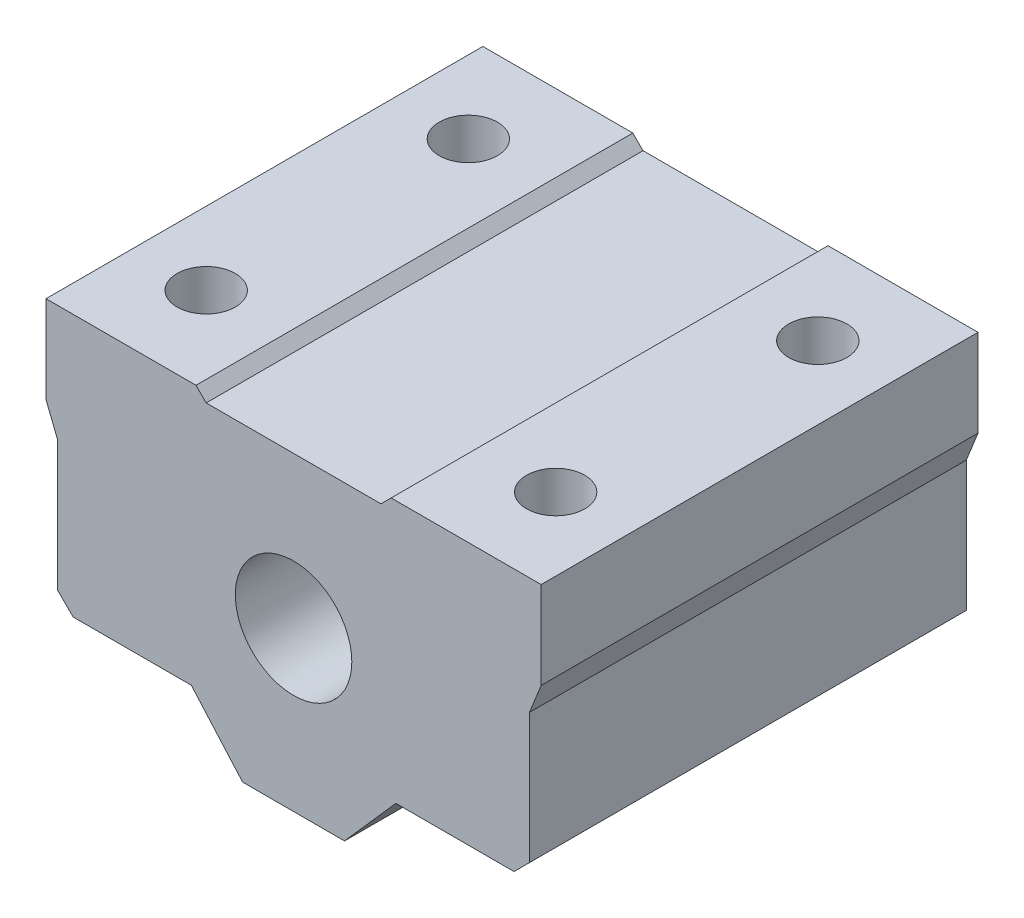
from build123d import *

# Parameters (mm, degrees)
SKETCH1_R           = 7.5
SKETCH1_R_2         = 4
BOSS_EXTRUDE1_DEPTH = 30
SKETCH4_R           = 2
CUT_EXTRUDE1_DEPTH  = 19


with BuildPart() as part:
    # Sketch1 → Boss-Extrude1 (new body)
    with BuildSketch(Plane.XY):
        Polygon((6.7, 11.09607963), (17, 11.09607963), (17, 5.09607963), (16.2, 3.09607963), (16.2, -5.843260198), (15.139339828, -6.90392037), (7.024607597, -6.90392037), (3.5, -10.90392037), (0, -10.90392037), (-3.5, -10.90392037), (-7.024607597, -6.90392037), (-15.139339828, -6.90392037), (-16.2, -5.843260198), (-16.2, 3.09607963), (-17, 5.09607963), (-17, 11.09607963), (-6.7, 11.09607963), (-6, 10.39607963), (6, 10.39607963), align=None)
        Circle(SKETCH1_R, mode=Mode.SUBTRACT)
        Circle(SKETCH1_R)
        Circle(SKETCH1_R_2, mode=Mode.SUBTRACT)
    extrude(amount=BOSS_EXTRUDE1_DEPTH)

    # Sketch4 → Cut-Extrude1 (cut, through all)
    with BuildSketch(Plane.XZ.offset(6.90392037)):
        with Locations((-12, 24)):
            Circle(SKETCH4_R)
        with Locations((-12, 6)):
            Circle(SKETCH4_R)
        with Locations((12, 6)):
            Circle(SKETCH4_R)
        with Locations((12, 24)):
            Circle(SKETCH4_R)
    extrude(amount=-CUT_EXTRUDE1_DEPTH, mode=Mode.SUBTRACT)


solid = part.part
